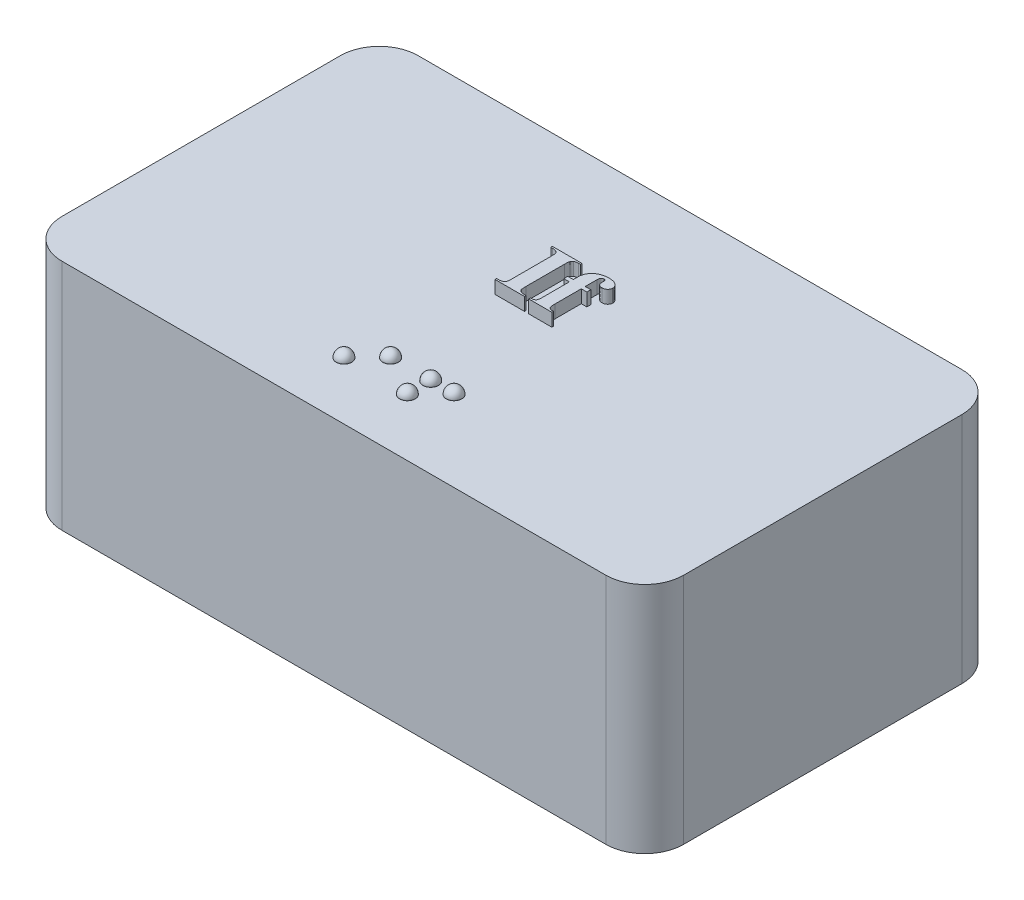
from build123d import *

# Parameters (mm, degrees)
SKETCH1_W           = 60.96
SKETCH1_H           = 34.925
BOSS_EXTRUDE1_DEPTH = 22.86
BOSS_EXTRUDE3_DEPTH = 1.27
SKETCH3_R           = 0.762
BOSS_EXTRUDE4_DEPTH = 0.0254
SKETCH6_R           = 3.1499937
CUT_EXTRUDE1_DEPTH  = 3.25
SKETCH7_W           = 41.656
SKETCH7_H           = 22.86
CUT_EXTRUDE2_DEPTH  = 17.78
FILLET2_R           = 3.81
SKETCH8_W           = 8.128
SKETCH8_H           = 8.128
BOSS_EXTRUDE5_DEPTH = 13.97
SKETCH9_R           = 1.7018
CUT_EXTRUDE3_DEPTH  = 12.7
DOME51_FACE_RADIUS  = 0.762
DOME51_HEIGHT       = 0.762
DOME52_FACE_RADIUS  = 0.762
DOME52_HEIGHT       = 0.762
DOME53_FACE_RADIUS  = 0.762
DOME53_HEIGHT       = 0.762
DOME54_FACE_RADIUS  = 0.762
DOME54_HEIGHT       = 0.762
DOME55_FACE_RADIUS  = 0.762
DOME55_HEIGHT       = 0.762


with BuildPart() as part:
    # Sketch1 → Boss-Extrude1 (new body)
    with BuildSketch(Plane(origin=(0, 0, 0), x_dir=(1, 0, 0), z_dir=(0, 1, 0))):
        Rectangle(SKETCH1_W, SKETCH1_H)
    extrude(amount=BOSS_EXTRUDE1_DEPTH)

    # Sketch2 → Boss-Extrude3 (add)
    with BuildSketch(Plane(origin=(0, 22.86, 0), x_dir=(1, 0, 0), z_dir=(0, 1, 0))):
        with BuildLine():
            Line((0.273478378, 1.108773359), (0.273478378, 0.9525))
            Line((0.273478378, 0.9525), (-2.617578765, 0.9525))
            Line((-2.617578765, 0.9525), (-2.617578765, 1.108773359))
            Line((-2.617578765, 1.108773359), (-2.433225037, 1.108773359))
            add(Edge.make_bspline(
                [(-2.433225037, 1.108773359), (-2.394899145, 1.109489272), (-2.321948197, 1.110851968), (-2.218274406, 1.127047435), (-2.125732109, 1.152696122), (-2.071100567, 1.179974003), (-2.044983411, 1.193014467)],
                knots=[0, 0, 0, 0, 0.000114867, 0.000218642, 0.000314067, 0.000401469, 0.000401469, 0.000401469, 0.000401469], degree=3))
            add(Edge.make_bspline(
                [(-2.044983411, 1.193014467), (-2.027825426, 1.203365035), (-1.993118773, 1.224301853), (-1.94854465, 1.268651716), (-1.910771504, 1.322713651), (-1.89137944, 1.363613604), (-1.881384738, 1.384693509)],
                knots=[0, 0, 0, 0, 5.9935e-05, 0.000121236, 0.000186948, 0.000256838, 0.000256838, 0.000256838, 0.000256838], degree=3))
            add(Edge.make_bspline(
                [(-1.881384738, 1.384693509), (-1.877397015, 1.394363917), (-1.868313144, 1.416392717), (-1.861559287, 1.455896821), (-1.851766055, 1.503982977), (-1.846824133, 1.562496048), (-1.841838762, 1.630840766), (-1.837952764, 1.708595691), (-1.837545229, 1.796134853), (-1.836673702, 1.857584417), (-1.83621197, 1.890140155)],
                knots=[0, 0, 0, 0, 3.1294e-05, 7.1286e-05, 0.000119661, 0.000178581, 0.000247125, 0.000325347, 0.000412039, 0.000509717, 0.000509717, 0.000509717, 0.000509717], degree=3))
            Line((-1.83621197, 1.890140155), (-1.83621197, 5.640700774))
            add(Edge.make_bspline(
                [(-1.83621197, 5.640700774), (-1.83667915, 5.673663257), (-1.837573142, 5.736740067), (-1.837903191, 5.826316682), (-1.841870254, 5.906098005), (-1.846751513, 5.975684764), (-1.852079626, 6.036149033), (-1.861257345, 6.086406313), (-1.868546461, 6.127758819), (-1.883909948, 6.169167429), (-1.908378467, 6.214418507), (-1.949843637, 6.262113833), (-2.001901402, 6.306174692), (-2.064653836, 6.346803497), (-2.139498867, 6.381330525), (-2.226942416, 6.404901963), (-2.326093813, 6.419770759), (-2.396131002, 6.421272302), (-2.433225037, 6.42206757)],
                knots=[0, 0, 0, 0, 9.8899e-05, 0.000189253, 0.000268695, 0.000338457, 0.000398591, 0.000450575, 0.000491761, 0.000524201, 0.000582663, 0.000645036, 0.000712572, 0.000786735, 0.00086868, 0.000958736, 0.0010575, 0.001168708, 0.001168708, 0.001168708, 0.001168708], degree=3))
            Line((-2.433225037, 6.42206757), (-2.617578765, 6.42206757))
            Line((-2.617578765, 6.42206757), (-2.617578765, 6.578340929))
            Line((-2.617578765, 6.578340929), (0.273478378, 6.578340929))
            Line((0.273478378, 6.578340929), (0.273478378, 6.42206757))
            Line((0.273478378, 6.42206757), (0.090345536, 6.42206757))
            add(Edge.make_bspline(
                [(0.090345536, 6.42206757), (0.052024001, 6.421336688), (-0.020918654, 6.419945502), (-0.124261836, 6.404002467), (-0.216253189, 6.377886811), (-0.270550512, 6.350839868), (-0.296675205, 6.337826462)],
                knots=[0, 0, 0, 0, 0.000114867, 0.000218642, 0.000312896, 0.000400298, 0.000400298, 0.000400298, 0.000400298], degree=3))
            add(Edge.make_bspline(
                [(-0.296675205, 6.337826462), (-0.313849893, 6.327488778), (-0.348590332, 6.306578023), (-0.393068842, 6.261855099), (-0.432151315, 6.208263505), (-0.452329541, 6.167255172), (-0.462715649, 6.14614742)],
                knots=[0, 0, 0, 0, 5.9935e-05, 0.000121236, 0.000187659, 0.000258112, 0.000258112, 0.000258112, 0.000258112], degree=3))
            add(Edge.make_bspline(
                [(-0.462715649, 6.14614742), (-0.466685053, 6.136473422), (-0.475576023, 6.114804873), (-0.482873161, 6.07541812), (-0.492147208, 6.027229198), (-0.497331165, 5.96835474), (-0.502200235, 5.900401635), (-0.506206202, 5.822655312), (-0.506531862, 5.735112158), (-0.507420642, 5.673256239), (-0.507888417, 5.640700774)],
                knots=[0, 0, 0, 0, 3.1294e-05, 7.0094e-05, 0.000119672, 0.000178591, 0.000247135, 0.000324138, 0.00041205, 0.000509729, 0.000509729, 0.000509729, 0.000509729], degree=3))
            Line((-0.507888417, 5.640700774), (-0.507888417, 1.890140155))
            add(Edge.make_bspline(
                [(-0.507888417, 1.890140155), (-0.507436536, 1.857176662), (-0.506571819, 1.79409792), (-0.506044722, 1.704534312), (-0.502700202, 1.624679789), (-0.495861249, 1.554784545), (-0.490421243, 1.494431838), (-0.483385767, 1.443346237), (-0.474121091, 1.402427363), (-0.45944082, 1.360409283), (-0.432527662, 1.316656565), (-0.392010719, 1.268621629), (-0.339697284, 1.224698528), (-0.277023357, 1.184027422), (-0.20215403, 1.149513488), (-0.114717871, 1.125938053), (-0.015967738, 1.111130744), (0.053659813, 1.109586826), (0.090345536, 1.108773359)],
                knots=[0, 0, 0, 0, 9.8899e-05, 0.000189253, 0.000268695, 0.000338553, 0.000399902, 0.000450491, 0.000493135, 0.000525574, 0.000583576, 0.000645949, 0.000713485, 0.000787648, 0.000869593, 0.000959649, 0.001058413, 0.001168401, 0.001168401, 0.001168401, 0.001168401], degree=3))
            Line((0.090345536, 1.108773359), (0.273478378, 1.108773359))
        make_face()
        with BuildLine():
            Line((2.403923782, 4.390513901), (2.403923782, 1.812003475))
            add(Edge.make_bspline(
                [(2.403923782, 1.812003475), (2.404124268, 1.777407407), (2.40450414, 1.711856436), (2.40822614, 1.618216251), (2.413977096, 1.53469397), (2.422434425, 1.461369634), (2.432808657, 1.397873172), (2.44768864, 1.34510532), (2.462504775, 1.300961179), (2.47680649, 1.277079587), (2.483281347, 1.266267604)],
                knots=[0, 0, 0, 0, 0.000103782, 0.000196642, 0.000281104, 0.000354854, 0.000418081, 0.000473762, 0.000519346, 0.000557055, 0.000557055, 0.000557055, 0.000557055], degree=3))
            add(Edge.make_bspline(
                [(2.483281347, 1.266267604), (2.507408514, 1.239456371), (2.557500453, 1.183791874), (2.66862407, 1.135958028), (2.801160573, 1.107457214), (2.898170079, 1.108309997), (2.950880539, 1.108773359)],
                knots=[0, 0, 0, 0, 0.000107063, 0.00022228, 0.000354705, 0.000512275, 0.000512275, 0.000512275, 0.000512275], degree=3))
            Line((2.950880539, 1.108773359), (2.950880539, 0.9525))
            Line((2.950880539, 0.9525), (0.684916832, 0.9525))
            Line((0.684916832, 0.9525), (0.684916832, 1.108773359))
            add(Edge.make_bspline(
                [(0.684916832, 1.108773359), (0.724044198, 1.110102995), (0.796846583, 1.112576983), (0.89644492, 1.12609507), (0.97894815, 1.143779578), (1.043673173, 1.172649812), (1.094266123, 1.208690974), (1.136784185, 1.248549874), (1.16856425, 1.296639677), (1.195782816, 1.353118295), (1.211242363, 1.429318002), (1.224710993, 1.529915144), (1.230600029, 1.660974382), (1.231420652, 1.758290612), (1.231873589, 1.812003475)],
                knots=[0, 0, 0, 0, 0.000117364, 0.000218373, 0.000301286, 0.00036959, 0.000429201, 0.000487048, 0.000543262, 0.000601161, 0.000674006, 0.000775015, 0.000905855, 0.001067031, 0.001067031, 0.001067031, 0.001067031], degree=3))
            Line((1.231873589, 1.812003475), (1.231873589, 4.390513901))
            Line((1.231873589, 4.390513901), (0.684916832, 4.390513901))
            Line((0.684916832, 4.390513901), (0.684916832, 4.781197299))
            Line((0.684916832, 4.781197299), (1.231873589, 4.781197299))
            Line((1.231873589, 4.781197299), (1.231873589, 5.066884533))
            Line((1.231873589, 5.066884533), (1.231873589, 5.262226232))
            add(Edge.make_bspline(
                [(1.231873589, 5.262226232), (1.233322289, 5.311137), (1.236172663, 5.407370846), (1.257403532, 5.548125608), (1.291586646, 5.682919219), (1.340413084, 5.811133249), (1.403808068, 5.933062795), (1.479085833, 6.0497962), (1.570803565, 6.15844697), (1.673862086, 6.261125099), (1.790140326, 6.353338499), (1.91580111, 6.435958839), (2.052586009, 6.50408618), (2.198299183, 6.560886086), (2.35452359, 6.602658321), (2.519596691, 6.635010584), (2.69490571, 6.653071407), (2.81491613, 6.655323626), (2.876406517, 6.656477608)],
                knots=[0, 0, 0, 0, 0.000146689, 0.000288617, 0.000426014, 0.000563194, 0.000699157, 0.000837656, 0.000978968, 0.001124868, 0.0012734, 0.001423415, 0.001575203, 0.001730965, 0.001891798, 0.002059647, 0.002235191, 0.002419646, 0.002419646, 0.002419646, 0.002419646], degree=3))
            add(Edge.make_bspline(
                [(2.876406517, 6.656477608), (2.918346905, 6.655757632), (2.999090637, 6.654371531), (3.116066359, 6.644261987), (3.224770663, 6.629183596), (3.325157474, 6.605867475), (3.417372779, 6.576356826), (3.501968981, 6.541939414), (3.577230478, 6.498276663), (3.663960002, 6.435020721), (3.754221691, 6.3485109), (3.835155292, 6.234649623), (3.885154847, 6.112587898), (3.891482145, 6.028152992), (3.894625122, 5.986211404)],
                knots=[0, 0, 0, 0, 0.000125805, 0.000242199, 0.000352011, 0.000454776, 0.000550916, 0.000642295, 0.000728158, 0.000811187, 0.000964012, 0.001100839, 0.001228028, 0.001353565, 0.001353565, 0.001353565, 0.001353565], degree=3))
            add(Edge.make_bspline(
                [(3.894625122, 5.986211404), (3.892714304, 5.953449557), (3.888939049, 5.888721109), (3.859565419, 5.794949829), (3.810952491, 5.708151595), (3.743821165, 5.630402238), (3.661044591, 5.56565842), (3.564346808, 5.518122237), (3.455067515, 5.489729581), (3.377957487, 5.486240093), (3.33790128, 5.484427415)],
                knots=[0, 0, 0, 0, 9.8158e-05, 0.000193933, 0.000291764, 0.00039479, 0.000500048, 0.000604881, 0.000715928, 0.000835973, 0.000835973, 0.000835973, 0.000835973], degree=3))
            add(Edge.make_bspline(
                [(3.33790128, 5.484427415), (3.303974801, 5.485653747), (3.238999658, 5.488002388), (3.147373016, 5.510747133), (3.065800663, 5.54583864), (2.998039557, 5.596484191), (2.942877863, 5.654423838), (2.9031004, 5.718010896), (2.876435836, 5.784759702), (2.873965379, 5.831329361), (2.87274386, 5.854355757)],
                knots=[0, 0, 0, 0, 0.000101598, 0.000194578, 0.000281475, 0.00036621, 0.000446539, 0.000520046, 0.00059035, 0.000659111, 0.000659111, 0.000659111, 0.000659111], degree=3))
            add(Edge.make_bspline(
                [(2.87274386, 5.854355757), (2.87274386, 5.862494995), (2.87274386, 5.882029165), (2.87274386, 5.916620924), (2.87274386, 5.960979768), (2.87274386, 5.99394368), (2.87274386, 6.011850002)],
                knots=[0, 0, 0, 0, 2.4418e-05, 5.8603e-05, 0.000103775, 0.000157494, 0.000157494, 0.000157494, 0.000157494], degree=3))
            add(Edge.make_bspline(
                [(2.87274386, 6.011850002), (2.87274386, 6.035453791), (2.87274386, 6.08103352), (2.87274386, 6.12661325), (2.87274386, 6.148589191)],
                knots=[0, 0, 0, 0, 7.0811e-05, 0.000136739, 0.000136739, 0.000136739, 0.000136739], degree=3))
            add(Edge.make_bspline(
                [(2.87274386, 6.148589191), (2.871551929, 6.175747155), (2.869390335, 6.224998765), (2.838835729, 6.263274727), (2.825129321, 6.280444838)],
                knots=[0, 0, 0, 0, 7.9085e-05, 0.000143422, 0.000143422, 0.000143422, 0.000143422], degree=3))
            add(Edge.make_bspline(
                [(2.825129321, 6.280444838), (2.803029401, 6.298961246), (2.758461971, 6.336302049), (2.700511803, 6.341373999), (2.671297733, 6.34393089)],
                knots=[0, 0, 0, 0, 8.4321e-05, 0.000170044, 0.000170044, 0.000170044, 0.000170044], degree=3))
            add(Edge.make_bspline(
                [(2.671297733, 6.34393089), (2.65283586, 6.34277278), (2.61709366, 6.340530678), (2.56534199, 6.32215183), (2.519208905, 6.29126376), (2.477790725, 6.248229546), (2.442864048, 6.192714067), (2.420894476, 6.121792218), (2.406031673, 6.03811723), (2.404660277, 5.977340734), (2.403923782, 5.944701293)],
                knots=[0, 0, 0, 0, 5.5278e-05, 0.000107018, 0.000162552, 0.000220399, 0.000285106, 0.000357304, 0.000441607, 0.000539399, 0.000539399, 0.000539399, 0.000539399], degree=3))
            Line((2.403923782, 5.944701293), (2.403923782, 5.252459147))
            Line((2.403923782, 5.252459147), (2.403923782, 4.781197299))
            Line((2.403923782, 4.781197299), (2.950880539, 4.781197299))
            Line((2.950880539, 4.781197299), (2.950880539, 4.390513901))
            Line((2.950880539, 4.390513901), (2.403923782, 4.390513901))
        make_face()
    extrude(amount=BOSS_EXTRUDE3_DEPTH)

    # Sketch3 → Boss-Extrude4 (add)
    with BuildSketch(Plane(origin=(0, 22.86, 0), x_dir=(1, 0, 0), z_dir=(0, 1, 0))):
        with Locations((1.5837885, -9.555062852)):
            Circle(SKETCH3_R)
        with Locations((-2.3532115, -9.555062852)):
            Circle(SKETCH3_R)
        with Locations((-4.6392115, -11.841062852)):
            Circle(SKETCH3_R)
        with Locations((1.5837885, -11.841062852)):
            Circle(SKETCH3_R)
        with Locations((3.8697885, -9.555062852)):
            Circle(SKETCH3_R)
    extrude(amount=BOSS_EXTRUDE4_DEPTH)

    # Sketch6 → Cut-Extrude1 (cut)
    with BuildSketch(Plane(origin=(0, 0, 0), x_dir=(-1, 0, 0), z_dir=(0, -1, 0))):
        with Locations((25.4, 0)):
            Circle(SKETCH6_R)
        with Locations((-25.4, 0)):
            Circle(SKETCH6_R)
    extrude(amount=-CUT_EXTRUDE1_DEPTH, mode=Mode.SUBTRACT)

    # Sketch7 → Cut-Extrude2 (cut)
    with BuildSketch(Plane(origin=(0, 0, 0), x_dir=(-1, 0, 0), z_dir=(0, -1, 0))):
        Rectangle(SKETCH7_W, SKETCH7_H)
    extrude(amount=-CUT_EXTRUDE2_DEPTH, mode=Mode.SUBTRACT)

    # Fillet2
    fillet2_edges = [part.edges().sort_by_distance(p)[0] for p in [
        (30.48, 11.43, 17.4625),
        (-30.48, 11.43, 17.4625),
        (-30.48, 11.43, -17.4625),
        (30.48, 11.43, -17.4625),
    ]]
    fillet(fillet2_edges, radius=FILLET2_R)

    # Sketch8 → Boss-Extrude5 (add)
    with BuildSketch(Plane.XZ.offset(-17.78)):
        with Locations((-16.764, 7.366)):
            Rectangle(SKETCH8_W, SKETCH8_H)
        with Locations((16.764, -7.366)):
            Rectangle(SKETCH8_W, SKETCH8_H)
    extrude(amount=BOSS_EXTRUDE5_DEPTH)

    # Sketch9 → Cut-Extrude3 (cut)
    with BuildSketch(Plane(origin=(0, 3.81, 0), x_dir=(-1, 0, 0), z_dir=(0, -1, 0))):
        with Locations((16.764, -7.366)):
            Circle(SKETCH9_R)
        with Locations((-16.764, 7.366)):
            Circle(SKETCH9_R)
    extrude(amount=-CUT_EXTRUDE3_DEPTH, mode=Mode.SUBTRACT)

    # Dome51: a dome of height H over a round flat face of radius A is a cap of a sphere of radius (A * A + H * H) / (2 * H)
    dome51_r = (DOME51_FACE_RADIUS * DOME51_FACE_RADIUS + DOME51_HEIGHT * DOME51_HEIGHT) / (2 * DOME51_HEIGHT)
    dome51_base = Plane((-4.6392115, 22.8854, 11.841062852), z_dir=(0, 1, 0))
    with Locations(dome51_base.offset(DOME51_HEIGHT - dome51_r)):
        dome51_ball = Sphere(dome51_r, mode=Mode.PRIVATE)
    add(split(dome51_ball, bisect_by=dome51_base, keep=Keep.TOP, mode=Mode.PRIVATE))

    # Dome52: a dome of height H over a round flat face of radius A is a cap of a sphere of radius (A * A + H * H) / (2 * H)
    dome52_r = (DOME52_FACE_RADIUS * DOME52_FACE_RADIUS + DOME52_HEIGHT * DOME52_HEIGHT) / (2 * DOME52_HEIGHT)
    dome52_base = Plane((-2.3532115, 22.8854, 9.555062852), z_dir=(0, 1, 0))
    with Locations(dome52_base.offset(DOME52_HEIGHT - dome52_r)):
        dome52_ball = Sphere(dome52_r, mode=Mode.PRIVATE)
    add(split(dome52_ball, bisect_by=dome52_base, keep=Keep.TOP, mode=Mode.PRIVATE))

    # Dome53: a dome of height H over a round flat face of radius A is a cap of a sphere of radius (A * A + H * H) / (2 * H)
    dome53_r = (DOME53_FACE_RADIUS * DOME53_FACE_RADIUS + DOME53_HEIGHT * DOME53_HEIGHT) / (2 * DOME53_HEIGHT)
    dome53_base = Plane((1.5837885, 22.8854, 9.555062852), z_dir=(0, 1, 0))
    with Locations(dome53_base.offset(DOME53_HEIGHT - dome53_r)):
        dome53_ball = Sphere(dome53_r, mode=Mode.PRIVATE)
    add(split(dome53_ball, bisect_by=dome53_base, keep=Keep.TOP, mode=Mode.PRIVATE))

    # Dome54: a dome of height H over a round flat face of radius A is a cap of a sphere of radius (A * A + H * H) / (2 * H)
    dome54_r = (DOME54_FACE_RADIUS * DOME54_FACE_RADIUS + DOME54_HEIGHT * DOME54_HEIGHT) / (2 * DOME54_HEIGHT)
    dome54_base = Plane((1.5837885, 22.8854, 11.841062852), z_dir=(0, 1, 0))
    with Locations(dome54_base.offset(DOME54_HEIGHT - dome54_r)):
        dome54_ball = Sphere(dome54_r, mode=Mode.PRIVATE)
    add(split(dome54_ball, bisect_by=dome54_base, keep=Keep.TOP, mode=Mode.PRIVATE))

    # Dome55: a dome of height H over a round flat face of radius A is a cap of a sphere of radius (A * A + H * H) / (2 * H)
    dome55_r = (DOME55_FACE_RADIUS * DOME55_FACE_RADIUS + DOME55_HEIGHT * DOME55_HEIGHT) / (2 * DOME55_HEIGHT)
    dome55_base = Plane((3.8697885, 22.8854, 9.555062852), z_dir=(0, 1, 0))
    with Locations(dome55_base.offset(DOME55_HEIGHT - dome55_r)):
        dome55_ball = Sphere(dome55_r, mode=Mode.PRIVATE)
    add(split(dome55_ball, bisect_by=dome55_base, keep=Keep.TOP, mode=Mode.PRIVATE))


solid = part.part
